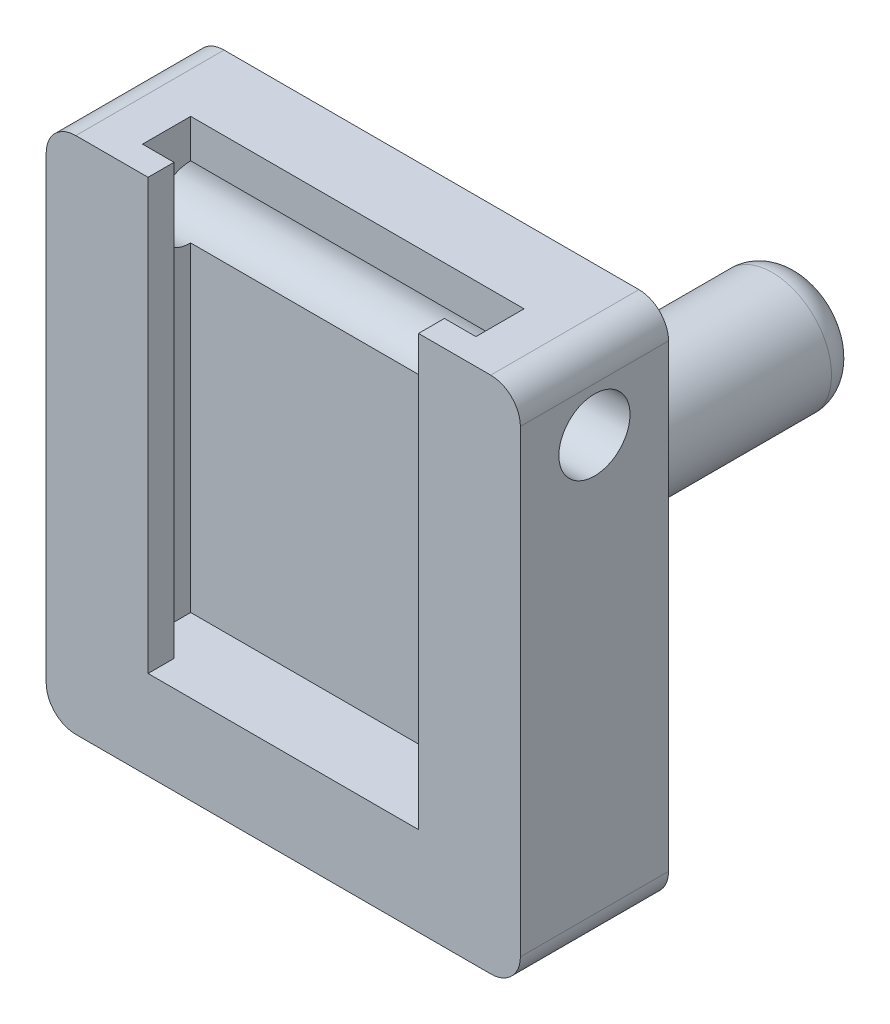
from build123d import *

# Parameters (mm, degrees)
SKETCH1_W               = 32
SKETCH1_H               = 27
BOSS_EXTRUDE1_DEPTH     = 10
SKETCH3_R               = 4
BOSS_EXTRUDE2_DEPTH     = 25
SKETCH4_W               = 32
SKETCH4_H               = 10
BOSS_EXTRUDE3_DEPTH     = 8
CUT_EXTRUDE4_DEPTH      = 9
CUT_EXTRUDE4_DEPTH_BACK = 21
SKETCH6_W               = 2.4
SKETCH6_H               = 32
FILLET1_R               = 2


with BuildPart() as part:
    # Sketch1 → Boss-Extrude1 (new body)
    with BuildSketch(Plane.XY):
        Rectangle(SKETCH1_W, SKETCH1_H)
    extrude(amount=BOSS_EXTRUDE1_DEPTH)

    # Sketch3 → Boss-Extrude2 (add)
    with BuildSketch(Plane(origin=(0, 0, 0), x_dir=(-1, 0, 0), z_dir=(0, 0, -1))):
        Circle(SKETCH3_R)
    extrude(amount=BOSS_EXTRUDE2_DEPTH)


with BuildPart() as body_2:
    # Sketch4 → Boss-Extrude3 (new body)
    with BuildSketch(Plane(origin=(0, 13.5, 0), x_dir=(1, 0, 0), z_dir=(0, 1, 0))):
        with Locations((0, -5)):
            Rectangle(SKETCH4_W, SKETCH4_H)
    extrude(amount=BOSS_EXTRUDE3_DEPTH)


with BuildPart() as cut_extrude4_tool:
    # Sketch2 → Cut-Extrude4 (new body, two sides)
    with BuildSketch(Plane(origin=(0, 13.5, 0), x_dir=(1, 0, 0), z_dir=(0, 1, 0))) as cut_extrude4_sk:
        Polygon((-9.125, -10), (-9.125, -8.25), (-11.25, -8.25), (-11.25, -5), (11.25, -5), (11.25, -8.25), (9.125, -8.25), (9.125, -10), align=None)
    extrude(amount=CUT_EXTRUDE4_DEPTH)
    extrude(cut_extrude4_sk.sketch, amount=-CUT_EXTRUDE4_DEPTH_BACK)


with BuildPart() as part_1:
    add(part.part)

    # Cut-Extrude4: cut by cut_extrude4_tool
    add(cut_extrude4_tool.part, mode=Mode.SUBTRACT)


with BuildPart() as body_2_1:
    add(body_2.part)

    # Cut-Extrude4: cut by cut_extrude4_tool
    add(cut_extrude4_tool.part, mode=Mode.SUBTRACT)

    # Sketch6 → M4 Clearance Hole1 (revolve, cut)
    with BuildSketch(Plane(origin=(-16, 16.5, 5), x_dir=(0, 0, 1), z_dir=(0, 1, 0))):
        with Locations((1.2, 16)):
            Rectangle(SKETCH6_W, SKETCH6_H)
    revolve(axis=Axis((-22.35, 16.5, 5), (1, 0, 0)), mode=Mode.SUBTRACT)

    # Combine1: union part
    add(part_1.part)

    # Fillet1
    fillet1_edges = [body_2_1.edges().sort_by_distance(p)[0] for p in [
        (16, 21.5, 5),
        (-16, 21.5, 5),
        (-16, -13.5, 5),
        (16, -13.5, 5),
        (4, 0, 0),
        (4, 0, -25),
    ]]
    fillet(fillet1_edges, radius=FILLET1_R)


solid = body_2_1.part
